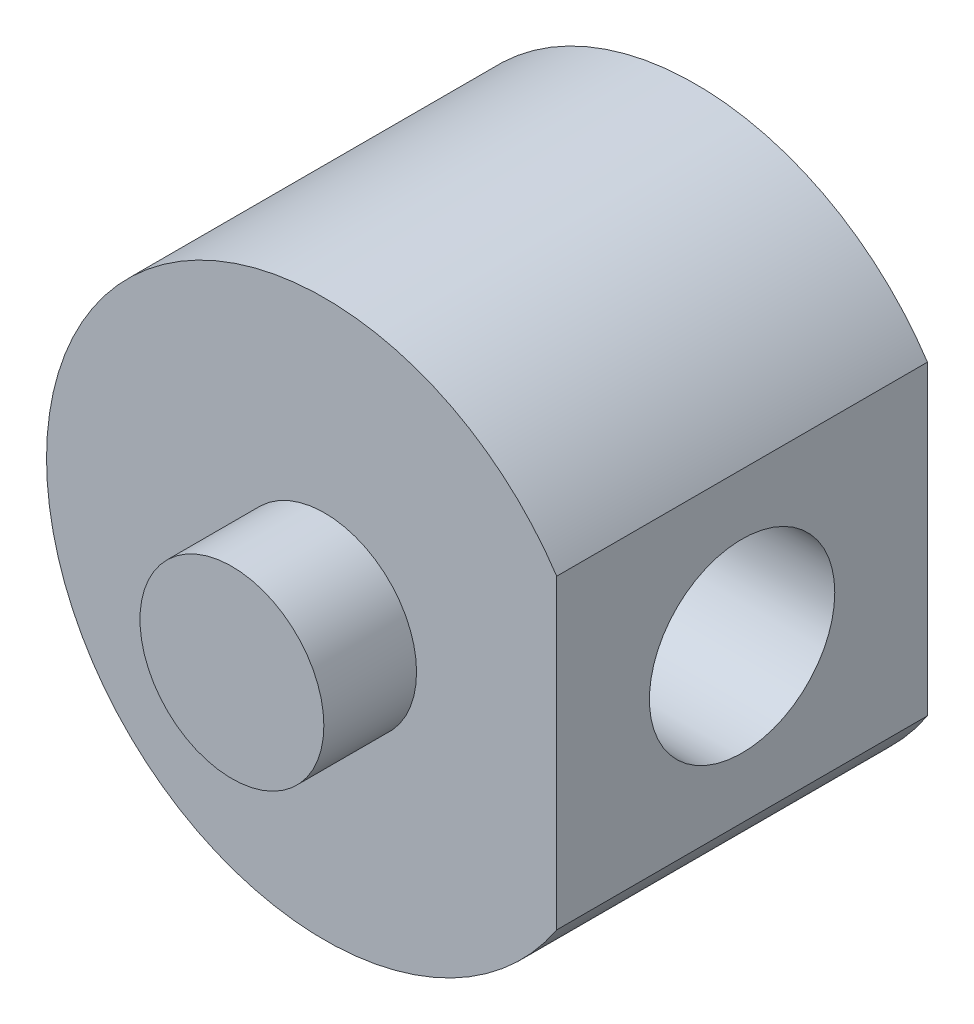
from build123d import *

# Parameters (mm, degrees)
BOSS_EXTRUDE1_DEPTH = 2.5
SKETCH4_R           = 1.24
BOSS_EXTRUDE2_DEPTH = 1.25
SKETCH5_R           = 1.25
CUT_EXTRUDE2_DEPTH  = 9.686737017
SKETCH7_R           = 1.875
CUT_EXTRUDE3_DEPTH  = 8.25
SKETCH8_R           = 1.875
BOSS_EXTRUDE3_DEPTH = 4.4
SKETCH5_3_R         = 1.25
CUT_EXTRUDE4_DEPTH  = 9.686737139


with BuildPart() as part:
    # Sketch3 → Boss-Extrude1 (new, symmetric)
    with BuildSketch(Plane.XY):
        with BuildLine():
            Line((3.13, -2.065332903), (3.13, 2.065332903))
            ThreePointArc((3.13, 2.065332903), (-3.75, 0), (3.13, -2.065332903))
        make_face()
    extrude(amount=BOSS_EXTRUDE1_DEPTH, both=True)

    # Sketch4 → Boss-Extrude2 (add)
    with BuildSketch(Plane.XY.offset(2.5)):
        Circle(SKETCH4_R)
    boss_extrude2 = extrude(amount=BOSS_EXTRUDE2_DEPTH)

    # Mirror1: Boss-Extrude2 across plane
    add(boss_extrude2.mirror(Plane.XY))

    # Sketch5 → Cut-Extrude2 (cut, through all)
    with BuildSketch(Plane(origin=(3.13, 0, 0), x_dir=(0, 0, -1), z_dir=(1, 0, 0))):
        Circle(SKETCH5_R)
    extrude(amount=-CUT_EXTRUDE2_DEPTH, mode=Mode.SUBTRACT)

    # Sketch7 → Cut-Extrude3 (cut)
    with BuildSketch(Plane(origin=(3.13, 0, 0), x_dir=(0, 0, -1), z_dir=(1, 0, 0))):
        Circle(SKETCH7_R)
    extrude(amount=-CUT_EXTRUDE3_DEPTH, mode=Mode.SUBTRACT)

    # Sketch8 → Boss-Extrude3 (add)
    with BuildSketch(Plane(origin=(3.13, 0, 0), x_dir=(0, 0, -1), z_dir=(1, 0, 0))):
        Circle(SKETCH8_R)
    extrude(amount=-BOSS_EXTRUDE3_DEPTH)

    # Sketch5_3 → Cut-Extrude4 (cut, through all)
    with BuildSketch(Plane(origin=(3.13, 0, 0), x_dir=(0, 0, -1), z_dir=(1, 0, 0))):
        Circle(SKETCH5_3_R)
    extrude(amount=-CUT_EXTRUDE4_DEPTH, mode=Mode.SUBTRACT)


solid = part.part
